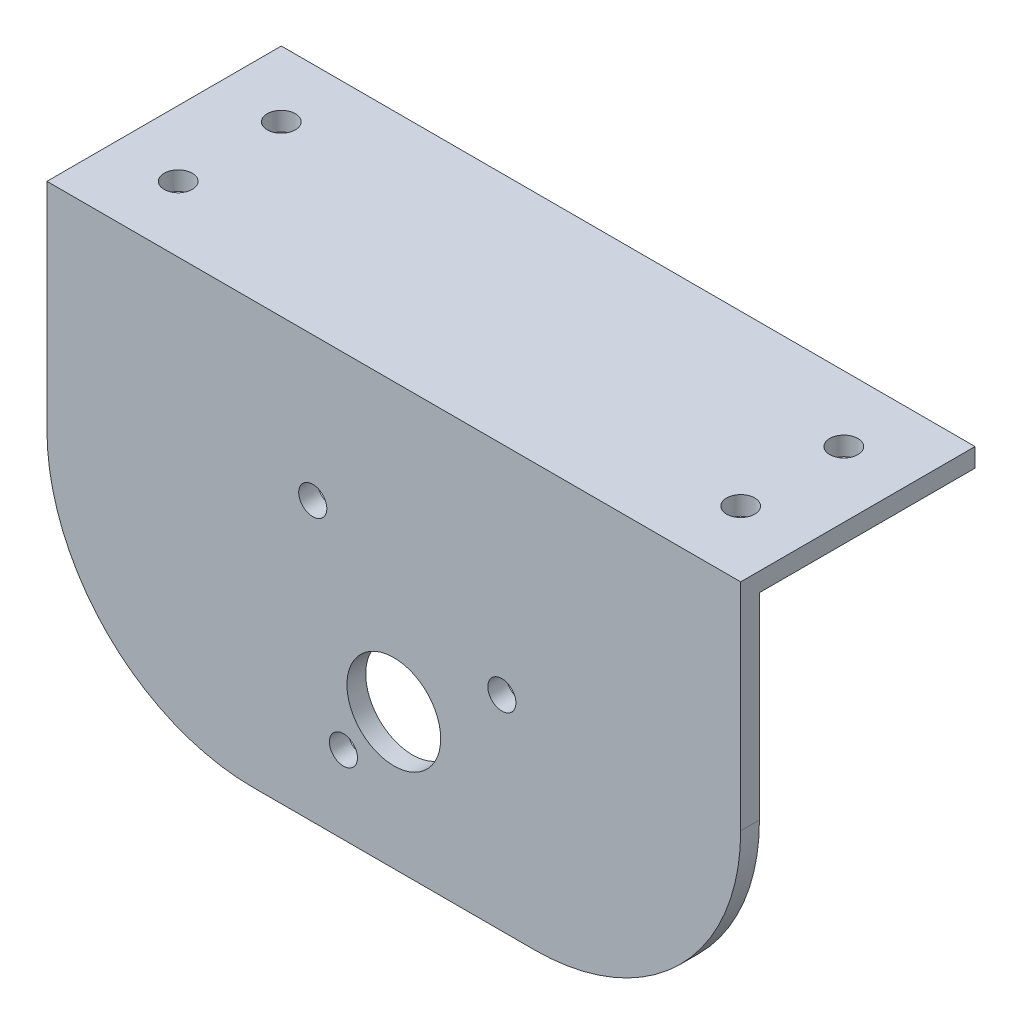
from build123d import *

# Parameters (mm, degrees)
SKETCH_1_W      = 74
SKETCH_1_H      = 25
SKETCH_1_R      = 1.5
EXTRUDE_1_DEPTH = 2
SKETCH_2_R      = 5
SKETCH_2_R_2    = 1.5
EXTRUDE_2_DEPTH = 2


with BuildPart() as part:
    # Эскиз1 → Бобышка-Вытянуть1 (new body)
    with BuildSketch(Plane(origin=(0, 0, 0), x_dir=(1, 0, 0), z_dir=(0, 1, 0))):
        with Locations((37, 12.5)):
            Rectangle(SKETCH_1_W, SKETCH_1_H)
        with Locations((7, 18)):
            Circle(SKETCH_1_R, mode=Mode.SUBTRACT)
        with Locations((67, 18)):
            Circle(SKETCH_1_R, mode=Mode.SUBTRACT)
        with Locations((7, 7)):
            Circle(SKETCH_1_R, mode=Mode.SUBTRACT)
        with Locations((67, 7)):
            Circle(SKETCH_1_R, mode=Mode.SUBTRACT)
    extrude(amount=EXTRUDE_1_DEPTH)

    # Эскиз2 → Бобышка-Вытянуть2 (add)
    with BuildSketch(Plane.XY):
        with BuildLine():
            Line((0, 2), (74, 2))
            Line((74, 2), (74, -21))
            ThreePointArc((74, -21), (67.556349186, -36.556349186), (52, -43))
            Line((52, -43), (22, -43))
            ThreePointArc((22, -43), (6.443650814, -36.556349186), (0, -21))
            Line((0, -21), (0, 2))
        make_face()
        with Locations((37, -28.5)):
            Circle(SKETCH_2_R, mode=Mode.SUBTRACT)
        with Locations((28.354168617, -13.306972233)):
            Circle(SKETCH_2_R_2, mode=Mode.SUBTRACT)
        with Locations((48.525028222, -21.173764644)):
            Circle(SKETCH_2_R_2, mode=Mode.SUBTRACT)
        with Locations((31.626756345, -34.708845272)):
            Circle(SKETCH_2_R_2, mode=Mode.SUBTRACT)
    extrude(amount=-EXTRUDE_2_DEPTH)


solid = part.part
